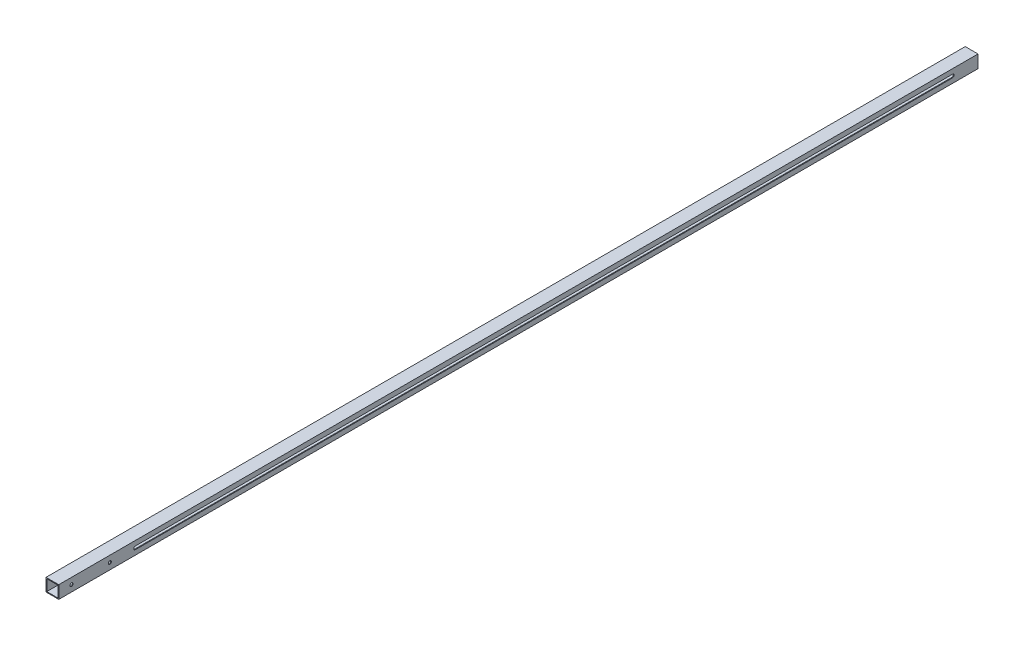
from build123d import *

# Parameters (mm, degrees)
SKETCH1_W           = 25.4
SKETCH1_H           = 25.4
SKETCH1_W_2         = 22.225
SKETCH1_H_2         = 22.225
BOSS_EXTRUDE1_DEPTH = 1828.8
SKETCH2_R           = 3.175
CUT_EXTRUDE1_DEPTH  = 26.4
CUT_EXTRUDE2_DEPTH  = 26.4


with BuildPart() as part:
    # Sketch1 → Boss-Extrude1 (new body)
    with BuildSketch(Plane.XY):
        Rectangle(SKETCH1_W, SKETCH1_H)
        Rectangle(SKETCH1_W_2, SKETCH1_H_2, mode=Mode.SUBTRACT)
    extrude(amount=BOSS_EXTRUDE1_DEPTH)

    # Sketch2 → Cut-Extrude1 (cut, through all)
    with BuildSketch(Plane(origin=(12.7, 0, 0), x_dir=(0, 0, -1), z_dir=(1, 0, 0))):
        with Locations((-1727.2, 0)):
            Circle(SKETCH2_R)
        with Locations((-1803.4, 0)):
            Circle(SKETCH2_R)
    extrude(amount=-CUT_EXTRUDE1_DEPTH, mode=Mode.SUBTRACT)

    # Sketch3 → Cut-Extrude2 (cut, through all)
    with BuildSketch(Plane(origin=(12.7, 0, 0), x_dir=(0, 0, -1), z_dir=(1, 0, 0))):
        with BuildLine():
            Line((-1676.4, 3.175), (-50.8, 3.175))
            ThreePointArc((-50.8, 3.175), (-47.625, 0), (-50.8, -3.175))
            Line((-50.8, -3.175), (-1676.4, -3.175))
            ThreePointArc((-1676.4, -3.175), (-1679.575, 0), (-1676.4, 3.175))
        make_face()
    extrude(amount=-CUT_EXTRUDE2_DEPTH, mode=Mode.SUBTRACT)


solid = part.part
